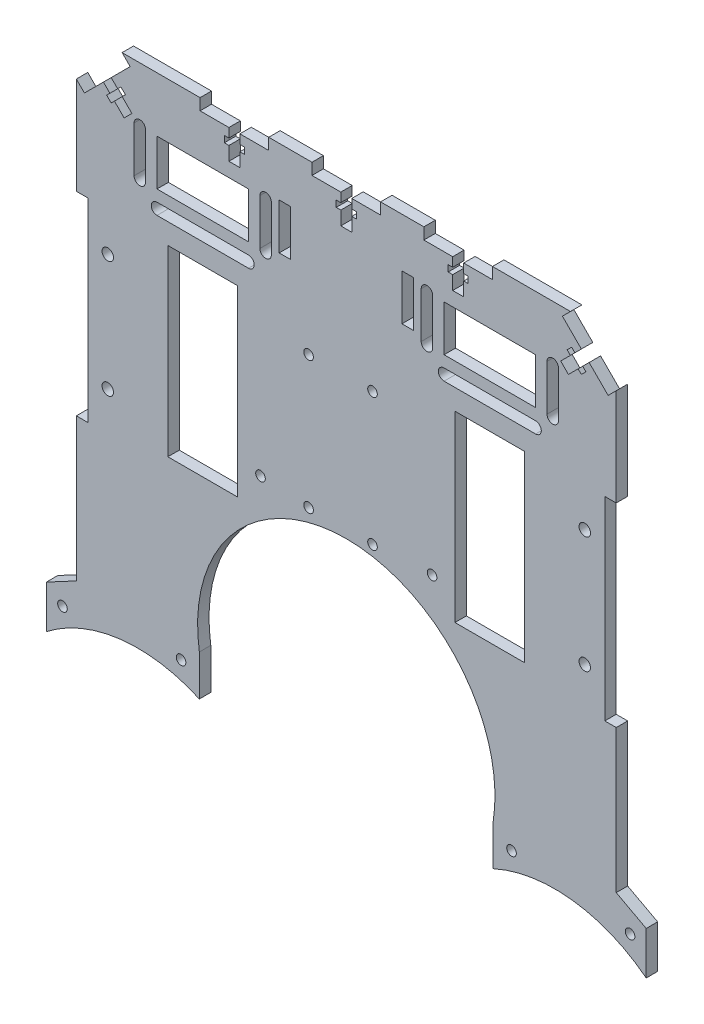
from build123d import *

# Parameters (mm, degrees)
SKETCH1_W           = 30.5
SKETCH1_H           = 80
BOSS_EXTRUDE1_DEPTH = 5
SKETCH4_W           = 5
SKETCH4_H           = 85
CUT_EXTRUDE3_DEPTH  = 6
SKETCH5_R           = 2.5
CUT_EXTRUDE4_DEPTH  = 6
CUT_EXTRUDE6_DEPTH  = 6
SKETCH8_R           = 2.1
CUT_EXTRUDE7_DEPTH  = 6
CUT_EXTRUDE8_DEPTH  = 5
SKETCH10_W          = 40
SKETCH10_H          = 20
CUT_EXTRUDE9_DEPTH  = 6
SKETCH13_W          = 5
SKETCH13_H          = 20.046380259
CUT_EXTRUDE10_DEPTH = 10
BOSS_EXTRUDE2_DEPTH = 5
SKETCH16_R          = 2.1
CUT_EXTRUDE12_DEPTH = 10
SKETCH17_R          = 2.1
CUT_EXTRUDE13_DEPTH = 6


with BuildPart() as part:
    # Sketch1 → Boss-Extrude1 (new body)
    with BuildSketch(Plane.XY):
        with BuildLine():
            Line((64.226162893, -107), (118, -107))
            Line((118, -107), (118, 83))
            Line((118, 83), (98, 103))
            Line((98, 103), (-98, 103))
            Line((-98, 103), (-118, 83))
            Line((-118, 83), (-118, -107))
            Line((-118, -107), (-64.226162893, -107))
            ThreePointArc((-64.226162893, -107), (0, -32), (64.226162893, -107))
        make_face()
        with Locations((62.75, 0)):
            Rectangle(SKETCH1_W, SKETCH1_H, mode=Mode.SUBTRACT)
        with Locations((-62.75, 0)):
            Rectangle(SKETCH1_W, SKETCH1_H, mode=Mode.SUBTRACT)
    extrude(amount=BOSS_EXTRUDE1_DEPTH)

    # Sketch4 → Cut-Extrude3 (cut, through all)
    with BuildSketch(Plane.XY.offset(5)):
        with Locations((-115.5, -2)):
            Rectangle(SKETCH4_W, SKETCH4_H)
        with Locations((115.5, -2)):
            Rectangle(SKETCH4_W, SKETCH4_H)
    extrude(amount=-CUT_EXTRUDE3_DEPTH, mode=Mode.SUBTRACT)

    # Sketch5 → Cut-Extrude4 (cut, through all)
    with BuildSketch(Plane(origin=(0, 0, 0), x_dir=(-1, 0, 0), z_dir=(0, 0, -1))):
        with Locations((-104.25, 23.5)):
            Circle(SKETCH5_R)
        with Locations((-104.25, -27.5)):
            Circle(SKETCH5_R)
        with Locations((104.25, 23.5)):
            Circle(SKETCH5_R)
        with Locations((104.25, -27.5)):
            Circle(SKETCH5_R)
    extrude(amount=-CUT_EXTRUDE4_DEPTH, mode=Mode.SUBTRACT)

    # Sketch7 → Cut-Extrude6 (cut, through all)
    with BuildSketch(Plane.XY.offset(5)):
        Polygon((-15, 98), (-2.4, 98), (-2.4, 94), (-4.4, 94), (-4.4, 91.2), (-2.4, 91.2), (-2.4, 85.2), (2.4, 85.2), (2.4, 91.2), (4.4, 91.2), (4.4, 94), (2.4, 94), (2.4, 98), (15, 98), (15, 103), (-15, 103), align=None)
        Polygon((-51.315063509, 98), (-63.915063509, 98), (-63.915063509, 103), (-33.915063509, 103), (-33.915063509, 98), (-46.515063509, 98), (-46.515063509, 94), (-44.515063509, 94), (-44.515063509, 91.2), (-46.515063509, 91.2), (-46.515063509, 85.2), (-51.315063509, 85.2), (-51.315063509, 91.2), (-53.315063509, 91.2), (-53.315063509, 94), (-51.315063509, 94), align=None)
        Polygon((-102.765899705, 91.163032483), (-99.93747258, 88.334605358), (-98.523259018, 89.748818921), (-96.543360031, 87.768919933), (-97.957573593, 86.354706371), (-93.714932906, 82.112065684), (-97.109045456, 78.717953134), (-101.351686143, 82.960593821), (-102.765899705, 81.546380259), (-104.745798693, 83.526279246), (-103.33158513, 84.940492808), (-106.160012255, 87.768919933), align=None)
        Polygon((93.714932906, 82.112065684), (97.109045456, 78.717953134), (101.351686143, 82.960593821), (102.765899705, 81.546380259), (104.745798693, 83.526279246), (103.33158513, 84.940492808), (106.160012255, 87.768919933), (102.765899705, 91.163032483), (99.93747258, 88.334605358), (98.523259018, 89.748818921), (96.543360031, 87.768919933), (97.957573593, 86.354706371), align=None)
        Polygon((33.915063509, 98), (46.515063509, 98), (46.515063509, 94), (44.515063509, 94), (44.515063509, 91.2), (46.515063509, 91.2), (46.515063509, 85.2), (51.315063509, 85.2), (51.315063509, 91.2), (53.315063509, 91.2), (53.315063509, 94), (51.315063509, 94), (51.315063509, 98), (63.915063509, 98), (63.915063509, 103), (33.915063509, 103), align=None)
    extrude(amount=-CUT_EXTRUDE6_DEPTH, mode=Mode.SUBTRACT)

    # Sketch8 → Cut-Extrude7 (cut, through all)
    with BuildSketch(Plane.XY.offset(5)):
        with Locations((-37.5, -27)):
            Circle(SKETCH8_R)
        with Locations((37.5, -27)):
            Circle(SKETCH8_R)
    extrude(amount=-CUT_EXTRUDE7_DEPTH, mode=Mode.SUBTRACT)

    # Sketch9 → Cut-Extrude8 (cut)
    with BuildSketch(Plane.XY.offset(5)):
        Polygon((94.467486322, 99.461445866), (98, 103), (118, 83), (114.464466094, 79.464466094), align=None)
        Polygon((-118, 83), (-114.461445866, 79.467486322), (-94.464466094, 99.464466094), (-98, 103), align=None)
    extrude(amount=-CUT_EXTRUDE8_DEPTH, mode=Mode.SUBTRACT)

    # Sketch10 → Cut-Extrude9 (cut, through all)
    with BuildSketch(Plane.XY.offset(5)):
        with Locations((62.75, 69)):
            Rectangle(SKETCH10_W, SKETCH10_H)
        with Locations((-62.75, 69)):
            Rectangle(SKETCH10_W, SKETCH10_H)
        with BuildLine():
            Line((-82.75, 54), (-42.75, 54))
            ThreePointArc((-42.75, 54), (-40.25, 51.5), (-42.75, 49))
            Line((-42.75, 49), (-82.75, 49))
            ThreePointArc((-82.75, 49), (-85.25, 51.5), (-82.75, 54))
        make_face()
        with BuildLine():
            Line((-32.75, 79), (-32.75, 59))
            ThreePointArc((-32.75, 59), (-35.25, 56.5), (-37.75, 59))
            Line((-37.75, 59), (-37.75, 79))
            ThreePointArc((-37.75, 79), (-35.25, 81.5), (-32.75, 79))
        make_face()
        with BuildLine():
            Line((-92.75, 79), (-92.75, 59))
            ThreePointArc((-92.75, 59), (-90.25, 56.5), (-87.75, 59))
            Line((-87.75, 59), (-87.75, 79))
            ThreePointArc((-87.75, 79), (-90.25, 81.5), (-92.75, 79))
        make_face()
        with BuildLine():
            Line((82.75, 54), (42.75, 54))
            ThreePointArc((42.75, 54), (40.25, 51.5), (42.75, 49))
            Line((42.75, 49), (82.75, 49))
            ThreePointArc((82.75, 49), (85.25, 51.5), (82.75, 54))
        make_face()
        with BuildLine():
            Line((32.75, 79), (32.75, 59))
            ThreePointArc((32.75, 59), (35.25, 56.5), (37.75, 59))
            Line((37.75, 59), (37.75, 79))
            ThreePointArc((37.75, 79), (35.25, 81.5), (32.75, 79))
        make_face()
        with BuildLine():
            Line((92.75, 79), (92.75, 59))
            ThreePointArc((92.75, 59), (90.25, 56.5), (87.75, 59))
            Line((87.75, 59), (87.75, 79))
            ThreePointArc((87.75, 79), (90.25, 81.5), (92.75, 79))
        make_face()
    extrude(amount=-CUT_EXTRUDE9_DEPTH, mode=Mode.SUBTRACT)

    # Sketch13 → Cut-Extrude10 (cut)
    with BuildSketch(Plane.XY.offset(5)):
        with Locations((-26.83400194, 71.52319013)):
            Rectangle(SKETCH13_W, SKETCH13_H)
        with Locations((26.83400194, 71.52319013)):
            Rectangle(SKETCH13_W, SKETCH13_H)
    extrude(amount=-CUT_EXTRUDE10_DEPTH, mode=Mode.SUBTRACT)

    # Sketch14 → Boss-Extrude2 (add)
    with BuildSketch(Plane(origin=(0, 0, 0), x_dir=(-1, 0, 0), z_dir=(0, 0, -1))):
        with BuildLine():
            Line((131.113081447, -114), (118, -107))
            Line((118, -107), (64.226162893, -107))
            Line((64.226162893, -107), (64.226162893, -124.821510574))
            ThreePointArc((64.226162893, -124.821510574), (98.778846905, -119.45361327), (131.113081447, -132.76524617))
            Line((131.113081447, -132.76524617), (131.113081447, -114))
        make_face()
        with BuildLine():
            Line((-64.226162893, -107), (-118, -107))
            Line((-118, -107), (-131.113081447, -114))
            Line((-131.113081447, -114), (-131.113081447, -132.76524617))
            ThreePointArc((-131.113081447, -132.76524617), (-98.778846905, -119.45361327), (-64.226162893, -124.821510574))
            Line((-64.226162893, -124.821510574), (-64.226162893, -107))
        make_face()
    extrude(amount=-BOSS_EXTRUDE2_DEPTH)

    # Sketch16 → Cut-Extrude12 (cut)
    with BuildSketch(Plane.XY.offset(5)):
        with Locations((124.055449987, -119.615682924)):
            Circle(SKETCH16_R)
        with Locations((72.228081447, -114)):
            Circle(SKETCH16_R)
        with Locations((-72.228081447, -114)):
            Circle(SKETCH16_R)
        with Locations((-124.055449987, -119.615682924)):
            Circle(SKETCH16_R)
    extrude(amount=-CUT_EXTRUDE12_DEPTH, mode=Mode.SUBTRACT)

    # Sketch17 → Cut-Extrude13 (cut, through all)
    with BuildSketch(Plane.XY.offset(5)):
        with Locations((-16.464466094, 29.464466094)):
            Circle(SKETCH17_R)
        with Locations((11.464466094, 29.464466094)):
            Circle(SKETCH17_R)
        with Locations((11.464466094, -28.464466094)):
            Circle(SKETCH17_R)
        with Locations((-16.464466094, -28.464466094)):
            Circle(SKETCH17_R)
    extrude(amount=-CUT_EXTRUDE13_DEPTH, mode=Mode.SUBTRACT)


solid = part.part
